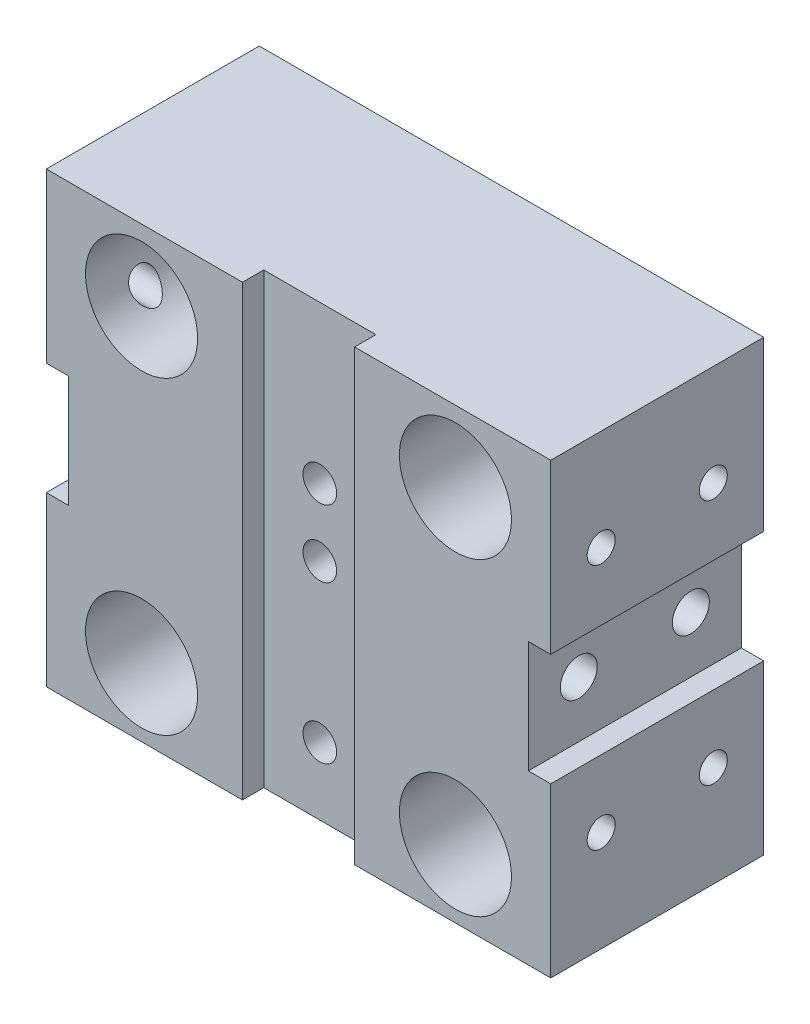
from build123d import *

# Parameters (mm, degrees)
BOSS_EXTRUDE1_DEPTH   = 19
SKETCH2_W             = 10
SKETCH2_H             = 40
CUT_EXTRUDE1_DEPTH    = 1.9
SKETCH3_R             = 5
CUT_EXTRUDE2_DEPTH    = 20
SKETCH4_R             = 4.25
CUT_EXTRUDE3_DEPTH    = 10
SKETCH5_R             = 1.5
CUT_EXTRUDE4_DEPTH    = 10
M3_TAPPED_HOLE2_D     = 2.5
M3_TAPPED_HOLE2_DEPTH = 7.5
M3_TAPPED_HOLE2_TIP   = 0.751075774
M4_TAPPED_HOLE1_D     = 3.3
M4_TAPPED_HOLE1_DEPTH = 10.1
M4_TAPPED_HOLE1_TIP   = 0.991420021
M4_TAPPED_HOLE2_D     = 3.3
M4_TAPPED_HOLE2_DEPTH = 10.1
M4_TAPPED_HOLE2_TIP   = 0.991420021
M3_TAPPED_HOLE3_D     = 2.5
M3_TAPPED_HOLE3_DEPTH = 7.5
M3_TAPPED_HOLE3_TIP   = 0.751075774


with BuildPart() as part:
    # Sketch1 → Boss-Extrude1 (new body)
    with BuildSketch(Plane.XY):
        Polygon((-19.512195122, -12.317073171), (-19.512195122, -27.317073171), (25.487804878, -27.317073171), (25.487804878, -12.317073171), (23.487804878, -12.317073171), (23.487804878, -2.317073171), (25.487804878, -2.317073171), (25.487804878, 12.682926829), (-19.512195122, 12.682926829), (-19.512195122, -2.317073171), (-17.512195122, -2.317073171), (-17.512195122, -12.317073171), align=None)
    extrude(amount=BOSS_EXTRUDE1_DEPTH)

    # Sketch2 → Cut-Extrude1 (cut)
    with BuildSketch(Plane.XY.offset(19)):
        with Locations((2.987804878, -7.317073171)):
            Rectangle(SKETCH2_W, SKETCH2_H)
    extrude(amount=-CUT_EXTRUDE1_DEPTH, mode=Mode.SUBTRACT)

    # Sketch3 → Cut-Extrude2 (cut, through all)
    with BuildSketch(Plane.XY.offset(19)):
        with Locations((-11.012195122, 6.337375375)):
            Circle(SKETCH3_R)
        with Locations((16.987804878, 6.337375375)):
            Circle(SKETCH3_R)
        with Locations((-11.012195122, -21.251537573)):
            Circle(SKETCH3_R)
        with Locations((16.987804878, -21.251537573)):
            Circle(SKETCH3_R)
    extrude(amount=-CUT_EXTRUDE2_DEPTH, mode=Mode.SUBTRACT)

    # Sketch4 → Cut-Extrude3 (cut)
    with BuildSketch(Plane(origin=(0, 0, 0), x_dir=(-1, 0, 0), z_dir=(0, 0, -1))):
        with Locations((-2.987804878, -19.317073171)):
            Circle(SKETCH4_R)
        with Locations((-2.987804878, 4.682926829)):
            Circle(SKETCH4_R)
    extrude(amount=-CUT_EXTRUDE3_DEPTH, mode=Mode.SUBTRACT)

    # Sketch5 → Cut-Extrude4 (cut)
    with BuildSketch(Plane.XY.offset(17.1)):
        with Locations((2.987804878, -1.317073171)):
            Circle(SKETCH5_R)
        with Locations((2.987804878, -7.317073171)):
            Circle(SKETCH5_R)
        with Locations((2.987804878, -21.317073171)):
            Circle(SKETCH5_R)
    extrude(amount=-CUT_EXTRUDE4_DEPTH, mode=Mode.SUBTRACT)

    # M3 Tapped Hole2
    with Locations(Plane.ZY.offset(19.512195122)):
        with Locations((14.5, 3.682926829), (4.5, 3.682926829), (14.5, -18.317073171), (4.5, -18.317073171)):
            Hole(M3_TAPPED_HOLE2_D / 2, depth=M3_TAPPED_HOLE2_DEPTH)
            with Locations((0, 0, -(M3_TAPPED_HOLE2_DEPTH + M3_TAPPED_HOLE2_TIP / 2))):  # 118° drill point
                Cone(0, M3_TAPPED_HOLE2_D / 2, M3_TAPPED_HOLE2_TIP, mode=Mode.SUBTRACT)

    # M4 Tapped Hole1
    with Locations(Plane.ZY.offset(17.512195122)):
        with Locations((14.5, -7.317073171), (4.5, -7.317073171)):
            Hole(M4_TAPPED_HOLE1_D / 2, depth=M4_TAPPED_HOLE1_DEPTH)
            with Locations((0, 0, -(M4_TAPPED_HOLE1_DEPTH + M4_TAPPED_HOLE1_TIP / 2))):  # 118° drill point
                Cone(0, M4_TAPPED_HOLE1_D / 2, M4_TAPPED_HOLE1_TIP, mode=Mode.SUBTRACT)

    # M4 Tapped Hole2
    with Locations(Plane(origin=(23.487804878, 0, 0), x_dir=(0, 0, -1), z_dir=(1, 0, 0))):
        with Locations((-14.5, -7.317073171), (-4.5, -7.317073171)):
            Hole(M4_TAPPED_HOLE2_D / 2, depth=M4_TAPPED_HOLE2_DEPTH)
            with Locations((0, 0, -(M4_TAPPED_HOLE2_DEPTH + M4_TAPPED_HOLE2_TIP / 2))):  # 118° drill point
                Cone(0, M4_TAPPED_HOLE2_D / 2, M4_TAPPED_HOLE2_TIP, mode=Mode.SUBTRACT)

    # M3 Tapped Hole3
    with Locations(Plane(origin=(25.487804878, 0, 0), x_dir=(0, 0, -1), z_dir=(1, 0, 0))):
        with Locations((-14.5, -18.317073171), (-4.5, -18.317073171), (-4.5, 3.682926829), (-14.5, 3.682926829)):
            Hole(M3_TAPPED_HOLE3_D / 2, depth=M3_TAPPED_HOLE3_DEPTH)
            with Locations((0, 0, -(M3_TAPPED_HOLE3_DEPTH + M3_TAPPED_HOLE3_TIP / 2))):  # 118° drill point
                Cone(0, M3_TAPPED_HOLE3_D / 2, M3_TAPPED_HOLE3_TIP, mode=Mode.SUBTRACT)


solid = part.part
